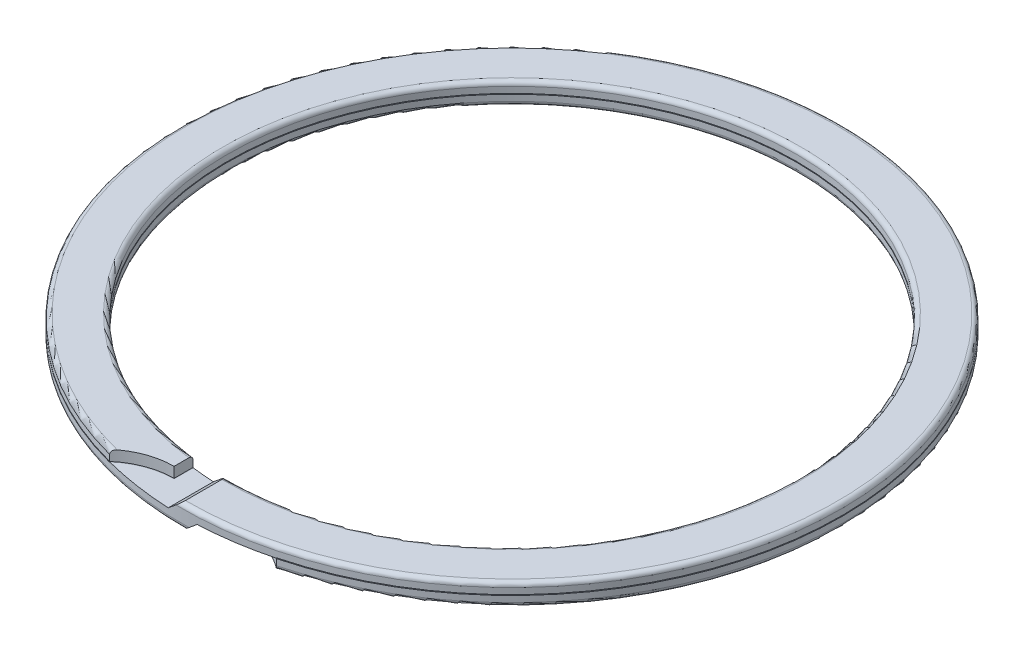
from build123d import *

# Parameters (mm, degrees)
EXTRUDE1_DEPTH      = 88.5
EXTRUDE2_DEPTH      = 88.5
EXTRUDE3_DEPTH      = 88.5
EXTRUDE4_DEPTH      = 88.5
EXTRUDE5_DEPTH      = 0.05
EXTRUDE5_DEPTH_BACK = 0.05


with BuildPart() as part:
    # Sketch1 → Revolve1 (revolve)
    with BuildSketch(Plane(origin=(0, 0, 0), x_dir=(0, 0, -1), z_dir=(1, 0, 0)), mode=Mode.PRIVATE) as revolve1_sk:
        with BuildLine():
            Line((38.2, 0.873), (38.2, -0.873))
            ThreePointArc((38.2, -0.873), (38.370463853, -1.284536147), (38.782, -1.455))
            Line((38.782, -1.455), (43.668, -1.455))
            ThreePointArc((43.668, -1.455), (44.079536147, -1.284536147), (44.25, -0.873))
            Line((44.25, -0.873), (44.25, 0.873))
            ThreePointArc((44.25, 0.873), (44.079536147, 1.284536147), (43.668, 1.455))
            Line((43.668, 1.455), (38.782, 1.455))
            ThreePointArc((38.782, 1.455), (38.370463853, 1.284536147), (38.2, 0.873))
        make_face()
    revolve(revolve1_sk.sketch.rotate(Axis((0, -1, 0), (0, 1, 0)), 180), axis=Axis((0, -1, 0), (0, 1, 0)))

    # Sketch2 → Extrude1 (cut)
    with BuildSketch(Plane(origin=(0, 0, 0), x_dir=(-1, 0, 0), z_dir=(0, 1, 0))):
        with BuildLine():
            Line((4.915666667, 59.605170172), (4.915666667, 40.446836943))
            ThreePointArc((4.915666667, 40.446836943), (14.495833333, 50.026003557), (4.915666667, 59.605170172))
        make_face()
    extrude(amount=EXTRUDE1_DEPTH, mode=Mode.SUBTRACT)

    # Sketch3 → Extrude2 (cut)
    with BuildSketch(Plane(origin=(0, 0, 0), x_dir=(-1, 0, 0), z_dir=(0, 1, 0))):
        with BuildLine():
            Line((-4.915666667, 40.446836943), (-4.915666667, 59.605170172))
            ThreePointArc((-4.915666667, 59.605170172), (-14.495833333, 50.026003557), (-4.915666667, 40.446836943))
        make_face()
    extrude(amount=-EXTRUDE2_DEPTH, mode=Mode.SUBTRACT)

    # Sketch4 → Extrude3 (cut)
    with BuildSketch(Plane.XY):
        Polygon((-4.916666667, 0), (-1.939393939, 0), (1.94, 3.2005), (-4.916666667, 3.2005), align=None)
    extrude(amount=EXTRUDE3_DEPTH, mode=Mode.SUBTRACT)

    # Sketch5 → Extrude4 (cut)
    with BuildSketch(Plane.XY):
        Polygon((-1.94, -3.2005), (4.916666667, -3.2005), (4.916666667, 0), (1.939393939, 0), align=None)
    extrude(amount=EXTRUDE4_DEPTH, mode=Mode.SUBTRACT)

    # Sketch6 → Extrude5 (cut, two sides)
    with BuildSketch(Plane(origin=(0, 0, 0), x_dir=(-1, 0, 0), z_dir=(0, 1, 0))) as extrude5_sk:
        with BuildLine():
            Line((45.135, -45.135), (45.135, 45.135))
            Line((45.135, 45.135), (13.153080827, 45.135))
            ThreePointArc((13.153080827, 45.135), (9.654834014, 41.700728534), (4.915666667, 40.446836943))
            Line((4.915666667, 40.446836943), (4.915666667, 37.872316027))
            ThreePointArc((4.915666667, 37.872316027), (0, 38.19), (-4.915666667, 37.872316027))
            Line((-4.915666667, 37.872316027), (-4.915666667, 40.446836943))
            ThreePointArc((-4.915666667, 40.446836943), (-9.654834014, 41.700728534), (-13.153080827, 45.135))
            Line((-13.153080827, 45.135), (-45.135, 45.135))
            Line((-45.135, 45.135), (-45.135, -45.135))
            Line((-45.135, -45.135), (45.135, -45.135))
        make_face()
    extrude(amount=EXTRUDE5_DEPTH, mode=Mode.SUBTRACT)
    extrude(extrude5_sk.sketch, amount=-EXTRUDE5_DEPTH_BACK, mode=Mode.SUBTRACT)


solid = part.part
